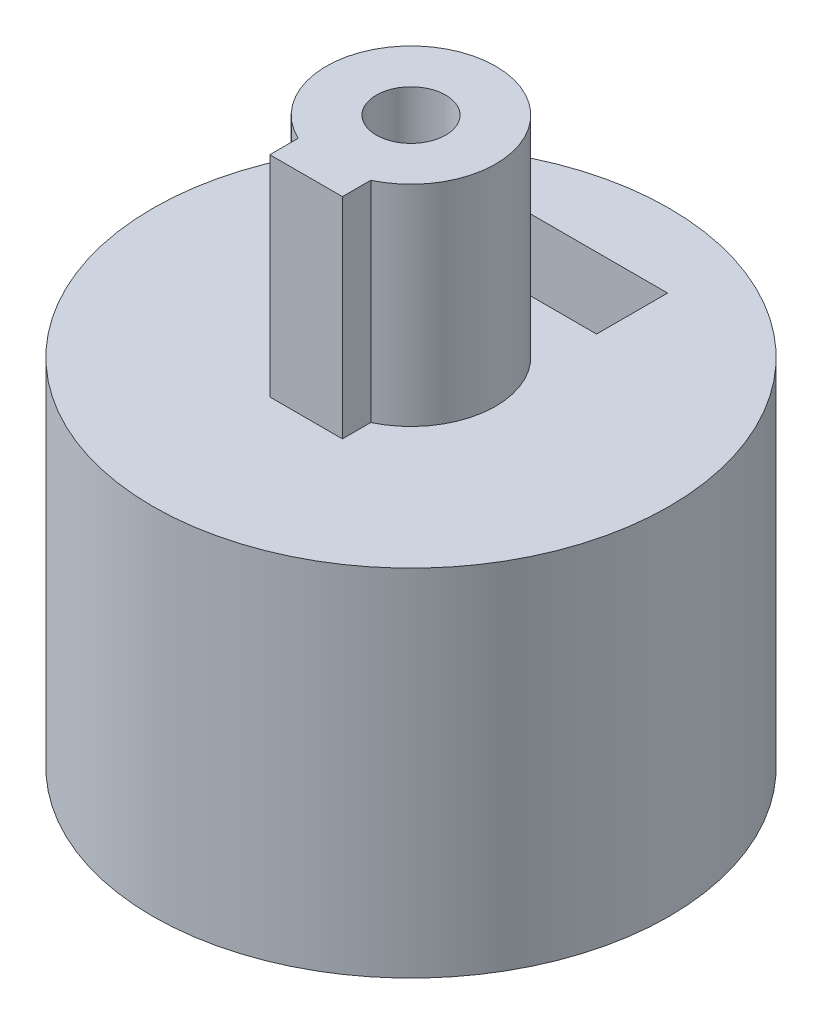
from build123d import *

# Parameters (mm, degrees)
SKETCH1_R           = 8
BOSS_EXTRUDE1_DEPTH = 10
SKETCH2_R           = 1.075
CUT_EXTRUDE1_DEPTH  = 9
SKETCH4_R           = 2.275
CUT_EXTRUDE4_DEPTH  = 11.0000001
SKETCH7_R           = 8
BOSS_EXTRUDE3_DEPTH = 1
SKETCH8_R           = 2.625
SKETCH8_W           = 2.25
SKETCH8_H           = 1.25
BOSS_EXTRUDE4_DEPTH = 6.5
SKETCH9_R           = 1.075
CUT_EXTRUDE5_DEPTH  = 6
CUT_EXTRUDE2_START  = -3.5
CUT_EXTRUDE2_DEPTH  = 2.2
SKETCH10_W          = 3.9924405
SKETCH10_H          = 2.148230377
BOSS_EXTRUDE5_DEPTH = 10


with BuildPart() as part:
    # Sketch1 → Boss-Extrude1 (new body)
    with BuildSketch(Plane(origin=(0, 0, 0), x_dir=(1, 0, 0), z_dir=(0, 1, 0))):
        Circle(SKETCH1_R)
    extrude(amount=BOSS_EXTRUDE1_DEPTH)

    # Sketch2 → Cut-Extrude1 (cut, through all)
    with BuildSketch(Plane.XY):
        with Locations((0, 7)):
            Circle(SKETCH2_R)
    extrude(amount=-CUT_EXTRUDE1_DEPTH, mode=Mode.SUBTRACT)

    # Sketch4 → Cut-Extrude4 (cut, through all)
    with BuildSketch(Plane(origin=(0, 0, 0), x_dir=(1, 0, 0), z_dir=(0, 1, 0))):
        Circle(SKETCH4_R)
    extrude(amount=CUT_EXTRUDE4_DEPTH, mode=Mode.SUBTRACT)

    # Sketch7 → Boss-Extrude3 (add)
    with BuildSketch(Plane(origin=(0, 10, 0), x_dir=(1, 0, 0), z_dir=(0, 1, 0))):
        Circle(SKETCH7_R)
    extrude(amount=BOSS_EXTRUDE3_DEPTH)

    # Sketch8 → Boss-Extrude4 (add)
    with BuildSketch(Plane(origin=(0, 11, 0), x_dir=(1, 0, 0), z_dir=(0, 1, 0))):
        Circle(SKETCH8_R)
        with Locations((0, -2.625)):
            Rectangle(SKETCH8_W, SKETCH8_H)
    extrude(amount=BOSS_EXTRUDE4_DEPTH)

    # Sketch9 → Cut-Extrude5 (cut)
    with BuildSketch(Plane(origin=(0, 17.5, 0), x_dir=(1, 0, 0), z_dir=(0, 1, 0))):
        Circle(SKETCH9_R)
    extrude(amount=-CUT_EXTRUDE5_DEPTH, mode=Mode.SUBTRACT)

    # Sketch3 → Cut-Extrude2 (cut)
    with BuildSketch(Plane.XY.offset(CUT_EXTRUDE2_START)):
        Polygon((0, 4.401923789), (2.25, 5.700961894), (2.25, 8.299038106), (2.25, 11.472802467), (-2.25, 11.472802467), (-2.25, 8.299038106), (-2.25, 5.700961894), align=None)
    extrude(amount=-CUT_EXTRUDE2_DEPTH, mode=Mode.SUBTRACT)

    # Sketch10 → Boss-Extrude5 (add)
    with BuildSketch(Plane.XZ):
        with Locations((-0.06344375, 2.274115189)):
            Rectangle(SKETCH10_W, SKETCH10_H)
    extrude(amount=-BOSS_EXTRUDE5_DEPTH)


solid = part.part
